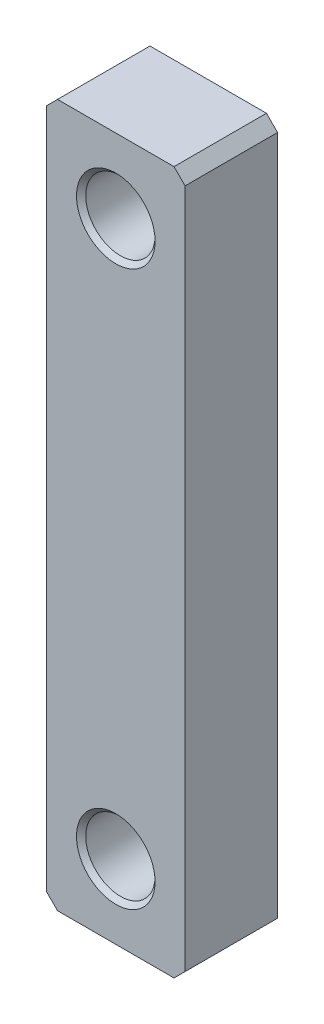
from build123d import *

# Parameters (mm, degrees)
SKETCH1_W                        = 19.05
SKETCH1_H                        = 96.52
BOSS_EXTRUDE1_DEPTH              = 12.7
F_3_8_16_TAPPED_HOLE1_AT_2_COUNT = 2
F_3_8_16_TAPPED_HOLE1_AT_2_PITCH = 76.2
CHAMFER1_SIZE                    = 1.524


with BuildPart() as part:
    # Sketch1 → Boss-Extrude1 (new body)
    with BuildSketch(Plane.XY):
        Rectangle(SKETCH1_W, SKETCH1_H)
    extrude(amount=-BOSS_EXTRUDE1_DEPTH)

    # Sketch18 → 3/8-16 Tapped Hole1 (revolve, cut)
    with BuildSketch(Plane(origin=(0, -38.1, 0), x_dir=(0, -1, 0), z_dir=(1, 0, 0))):
        Polygon((0, 0), (0, 29.384865582), (3.96875, 27.0002), (3.96875, 19.05), (4.7625, 19.05), (4.7625, 0.635), (5.3975, 0), align=None)
    f_3_8_16_tapped_hole1 = revolve(axis=Axis((0, -38.1, 6.35), (0, 0, -1)), mode=Mode.SUBTRACT)

    # 3/8-16 Tapped Hole1 at 2: 3/8-16 Tapped Hole1 ×2
    with Locations(*[(0, i * F_3_8_16_TAPPED_HOLE1_AT_2_PITCH, 0) for i in range(1, F_3_8_16_TAPPED_HOLE1_AT_2_COUNT)]):
        add(f_3_8_16_tapped_hole1, mode=Mode.SUBTRACT)

    # Chamfer1
    chamfer1_edges = [part.edges().sort_by_distance(p)[0] for p in [
        (-9.525, 48.26, -6.35),
        (9.525, 48.26, -6.35),
        (9.525, -48.26, -6.35),
        (-9.525, -48.26, -6.35),
    ]]
    chamfer(chamfer1_edges, length=CHAMFER1_SIZE)


solid = part.part
